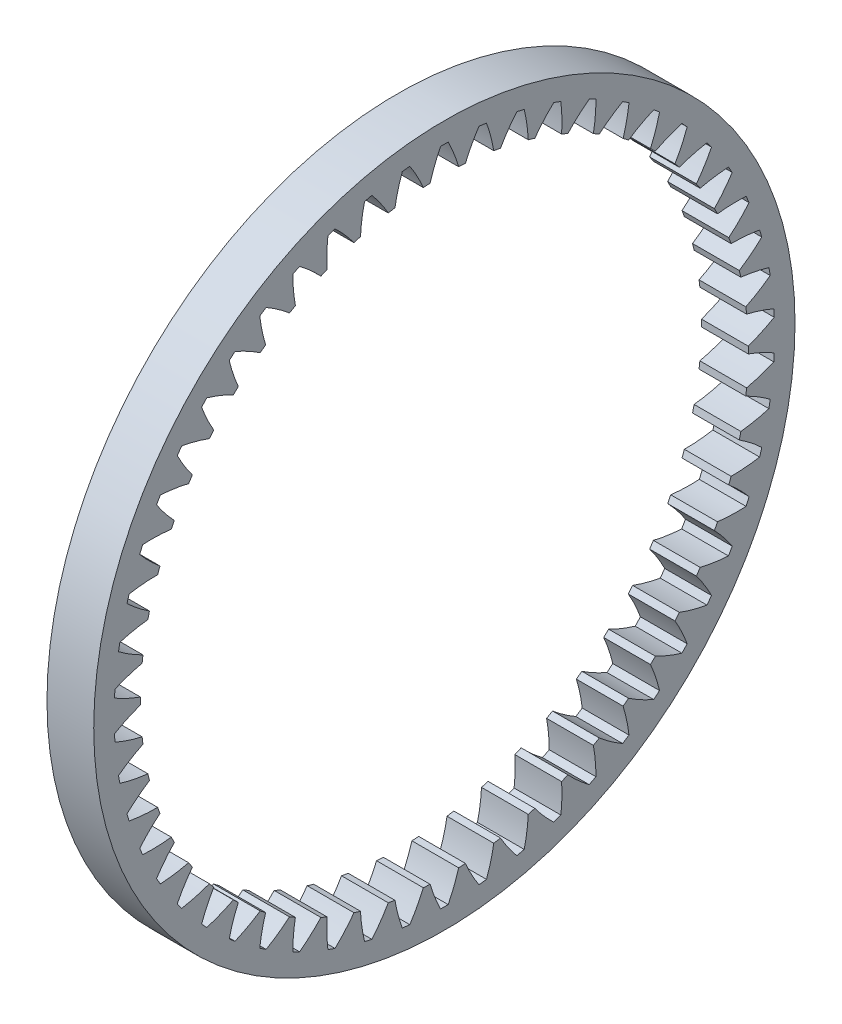
from build123d import *

# Parameters (mm, degrees)
BASPROSKE_W     = 4
BASPROSKE_H     = 4
TOOTHCUT_DEPTH  = 43.614551505
TEETHCUTS_COUNT = 54
TEETHCUTS_ANGLE = 353.333333333


with BuildPart() as part:
    # BasProSke → Base-Revolve (revolve)
    with BuildSketch(Plane(origin=(0, 0, 0), x_dir=(1, 0, 0), z_dir=(0, 1, 0))):
        with Locations((2, 28)):
            Rectangle(BASPROSKE_W, BASPROSKE_H)
    revolve(axis=Axis((-10, 0, 0), (1, 0, 0)))

    # TooCutSke → ToothCut (cut, through all)
    with BuildSketch(Plane(origin=(0, 0, 0), x_dir=(0, 0, -1), z_dir=(1, 0, 0))):
        with BuildLine():
            ThreePointArc((1.227935627, 25.945558758), (0.829152918, 27.118086898), (0.324594082, 28.249135202))
            ThreePointArc((0.324594082, 28.249135202), (0, 28.251), (-0.324594082, 28.249135202))
            ThreePointArc((-0.324594082, 28.249135202), (-0.829152918, 27.118086898), (-1.227935627, 25.945558758))
            ThreePointArc((-1.227935627, 25.945558758), (0, 25.9746), (1.227935627, 25.945558758))
        make_face()
    toothcut = extrude(amount=TOOTHCUT_DEPTH, mode=Mode.SUBTRACT)

    # TeethCuts: ToothCut ×54 about axis
    teethcuts_axis = Axis((-10, 0, 0), (1, 0, 0))
    for i in range(1, TEETHCUTS_COUNT):
        add(toothcut.rotate(teethcuts_axis, i * TEETHCUTS_ANGLE / (TEETHCUTS_COUNT - 1)), mode=Mode.SUBTRACT)


solid = part.part
